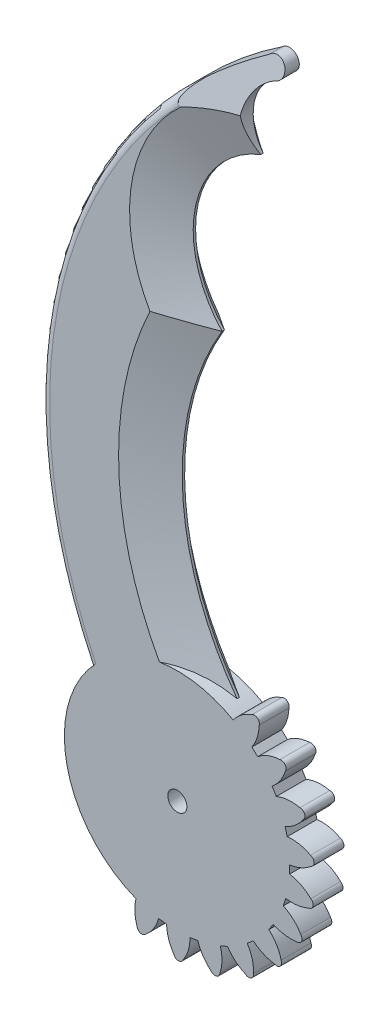
from build123d import *

# Parameters (mm, degrees)
CROQUIS1_R                         = 1.6
BASE_PINZA_IZQ_DEPTH               = 5
FILO_PINZA_IZQ_FRENTE_SIZE         = 2.5
FILO_PINZA_IZQ_FRENTE_SIZE2        = 8.177131546
FILO_PINZA_IZQ_FRENTE_PART_2_SIZE  = 2.5
FILO_PINZA_IZQ_FRENTE_PART_2_SIZE2 = 8.177131546
FILO_PINZA_IZQ_TRASERA_SIZE        = 2.5
FILO_PINZA_IZQ_TRASERA_SIZE2       = 2.097749078
REDONDEO_PINZA_R                   = 1.5
FILO_PUNTA_DE_LA_PINZA_DEPTH       = 25


with BuildPart() as part:
    # Croquis1 → Base pinza Izq (new body)
    with BuildSketch(Plane.XY):
        with BuildLine():
            Line((-3.21263052, -18.655749546), (-1.883787412, -18.818911478))
            ThreePointArc((-1.883787412, -18.818911478), (-1.540097921, -20.791041192), (-0.656756643, -22.587461594))
            ThreePointArc((-0.656756643, -22.587461594), (0.100167827, -23.142972839), (0.881978822, -22.623069999))
            ThreePointArc((0.881978822, -22.623069999), (1.764835319, -20.803692071), (2.039711322, -18.800191429))
            Line((2.039711322, -18.800191429), (3.362050825, -18.590753944))
            ThreePointArc((3.362050825, -18.590753944), (4.236018988, -20.391753035), (5.580301692, -21.875101303))
            ThreePointArc((5.580301692, -21.875101303), (6.461023842, -22.200456325), (7.069244162, -21.485197324))
            ThreePointArc((7.069244162, -21.485197324), (7.416411774, -19.492950781), (7.128399927, -17.491296261))
            Line((7.128399927, -17.491296261), (8.341785446, -16.925485865))
            ThreePointArc((8.341785446, -16.925485865), (9.678320191, -18.415819032), (11.379393858, -19.471170374))
            ThreePointArc((11.379393858, -19.471170374), (12.315678324, -19.54116177), (12.70318512, -18.685962448))
            ThreePointArc((12.70318512, -18.685962448), (12.487766478, -16.675199795), (11.659180963, -14.830472801))
            Line((11.659180963, -14.830472801), (12.669603503, -13.952126564))
            ThreePointArc((12.669603503, -13.952126564), (14.365154653, -15.016327849), (16.291225864, -15.561917222))
            ThreePointArc((16.291225864, -15.561917222), (17.2105325, -15.371122295), (17.347303061, -14.442240596))
            ThreePointArc((17.347303061, -14.442240596), (16.585988071, -12.568748903), (15.281024883, -11.023872625))
            Line((15.281024883, -11.023872625), (16.010200333, -9.901041834))
            ThreePointArc((16.010200333, -9.901041834), (17.933402334, -10.45666053), (19.935245626, -10.450217521))
            ThreePointArc((19.935245626, -10.450217521), (20.766349673, -10.013418415), (20.641787479, -9.082820943))
            ThreePointArc((20.641787479, -9.082820943), (19.393560244, -7.491751991), (17.713323504, -6.366418202))
            Line((17.713323504, -6.366418202), (18.104757824, -5.086095979))
            ThreePointArc((18.104757824, -5.086095979), (20.10660751, -5.090084635), (22.029126852, -4.532108425))
            ThreePointArc((22.029126852, -4.532108425), (22.707637188, -3.883146854), (22.331392895, -3.022933143))
            ThreePointArc((22.331392895, -3.022933143), (20.692961828, -1.837557559), (18.76763058, -1.218953305))
            Line((18.76763058, -1.218953305), (18.790996766, 0.119665328))
            ThreePointArc((18.790996766, 0.119665328), (20.716397612, 0.66761574), (22.410642729, 1.733895046))
            ThreePointArc((22.410642729, 1.733895046), (22.883990674, 2.544739741), (22.285214414, 3.267923249))
            ThreePointArc((22.285214414, 3.267923249), (20.383519596, 3.955766587), (18.362261974, 4.019713947))
            Line((18.362261974, 4.019713947), (18.015749693, 5.312917357))
            ThreePointArc((18.015749693, 5.312917357), (19.715528173, 6.370353498), (21.0502347, 7.862324196))
            ThreePointArc((21.0502347, 7.862324196), (21.28174686, 8.772230519), (20.506829787, 9.30235402))
            ThreePointArc((20.506829787, 9.30235402), (18.489208082, 9.439373341), (16.528624271, 8.943709383))
            Line((16.528624271, 8.943709383), (15.83908012, 10.091304558))
            ThreePointArc((15.83908012, 10.091304558), (17.181543163, 11.576299862), (18.053302564, 13.378369123))
            ThreePointArc((18.053302564, 13.378369123), (18.025042163, 14.316840617), (17.134022223, 14.61283194))
            ThreePointArc((17.134022223, 14.61283194), (15.156792117, 14.188411454), (13.408781501, 13.171538539))
            Line((13.408781501, 13.171538539), (12.429629021, 14.084613696))
            ThreePointArc((12.429629021, 14.084613696), (13.310767144, 15.882115764), (13.652038458, 17.854665374))
            ThreePointArc((13.652038458, 17.854665374), (13.366195015, 18.748992453), (12.428105411, 18.787919193))
            ThreePointArc((12.428105411, 18.787919193), (10.679055036, 17.860974772), (9.294318125, 16.446440621))
            ThreePointArc((9.294318125, 16.446440621), (8.383848535, 16.931404874), (7.448354327, 17.366141334))
            ThreePointArc((7.448354327, 17.366141334), (-1.700590628, 43.058240857), (4.930525057, 69.51226657))
            ThreePointArc((4.930525057, 69.51226657), (0.52306005, 85.704285694), (11.436802268, 98.451734925))
            ThreePointArc((11.436802268, 98.451734925), (9.950168374, 105.222634605), (14.191781062, 110.70568892))
            ThreePointArc((14.191781062, 110.70568892), (15.17222045, 113.125017455), (12.583169371, 113.458523773))
            ThreePointArc((12.583169371, 113.458523773), (-20.259146899, 67.82971774), (-14.824550004, 11.873745454))
            ThreePointArc((-14.824550004, 11.873745454), (-18.406509969, -4.886141091), (-7.013193513, -17.689131926))
            ThreePointArc((-7.013193513, -17.689131926), (-7.200569296, -19.632587419), (-6.848555023, -21.553059987))
            ThreePointArc((-6.848555023, -21.553059987), (-6.274072174, -22.295688328), (-5.379242566, -22.011421958))
            ThreePointArc((-5.379242566, -22.011421958), (-4.029097912, -20.505871876), (-3.21263052, -18.655749546))
        make_face()
        with Locations((-0.072580898, -0.041793431)):
            Circle(CROQUIS1_R, mode=Mode.SUBTRACT)
    extrude(amount=BASE_PINZA_IZQ_DEPTH)

    # Filo Pinza Izq frente
    filo_pinza_izq_frente_edges = [part.edges().sort_by_distance(p)[0] for p in [
        (-1.700590628, 43.058240857, 5),
    ]]
    filo_pinza_izq_frente_side = [part.faces().sort_by_distance(p)[0] for p in [
        (-1.700590628, 43.058240857, 2.5),
    ]]
    chamfer(filo_pinza_izq_frente_edges, length=FILO_PINZA_IZQ_FRENTE_SIZE, length2=FILO_PINZA_IZQ_FRENTE_SIZE2, reference=filo_pinza_izq_frente_side[0])

    # Filo Pinza Izq frente part 2
    filo_pinza_izq_frente_part_2_edges = [part.edges().sort_by_distance(p)[0] for p in [
        (0.52306005, 85.704285694, 5),
    ]]
    filo_pinza_izq_frente_part_2_side = [part.faces().sort_by_distance(p)[0] for p in [
        (0.52306005, 85.704285694, 2.5),
    ]]
    chamfer(filo_pinza_izq_frente_part_2_edges, length=FILO_PINZA_IZQ_FRENTE_PART_2_SIZE, length2=FILO_PINZA_IZQ_FRENTE_PART_2_SIZE2, reference=filo_pinza_izq_frente_part_2_side[0])

    # Filo Pinza Izq trasera
    filo_pinza_izq_trasera_edges = [part.edges().sort_by_distance(p)[0] for p in [
        (9.950168374, 105.222634605, 0),
        (0.52306005, 85.704285694, 0),
        (-1.700590628, 43.058240857, 0),
    ]]
    filo_pinza_izq_trasera_side = [part.faces().sort_by_distance(p)[0] for p in [
        (-4.202450513, 33.436926911, 0),
    ]]
    chamfer(filo_pinza_izq_trasera_edges, length=FILO_PINZA_IZQ_TRASERA_SIZE, length2=FILO_PINZA_IZQ_TRASERA_SIZE2, reference=filo_pinza_izq_trasera_side[0])

    # Redondeo pinza
    redondeo_pinza_edges = [part.edges().sort_by_distance(p)[0] for p in [
        (-20.259146899, 67.82971774, 5),
    ]]
    fillet(redondeo_pinza_edges, radius=REDONDEO_PINZA_R)

    # Croquis2 → Filo punta de la pinza (cut)
    with BuildSketch(Plane(origin=(0, 0, 0), x_dir=(0, 0, -1), z_dir=(1, 0, 0))):
        Polygon((-5, 101.169328416), (-1.113038662, 118.093846631), (-5, 118.093846631), align=None)
    extrude(amount=FILO_PUNTA_DE_LA_PINZA_DEPTH, mode=Mode.SUBTRACT)


solid = part.part
